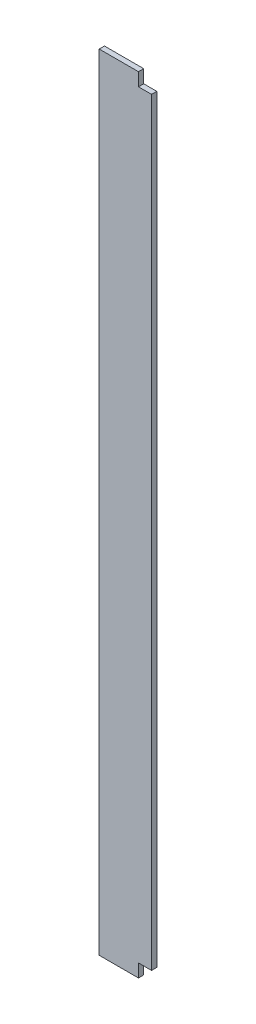
from build123d import *

# Parameters (mm, degrees)
ESBO_O1_W                = 200
ESBO_O1_H                = 20
RESSALTO_EXTRUS_O1_DEPTH = 3000
ESBO_O2_W                = 50
ESBO_O2_H                = 50
CORTE_EXTRUS_O1_DEPTH    = 21
ESBO_O3_W                = 50
ESBO_O3_H                = 50
CORTE_EXTRUS_O2_DEPTH    = 21


with BuildPart() as part:
    # Esboço1 → Ressalto-extrusão1 (new body)
    with BuildSketch(Plane(origin=(0, 0, 0), x_dir=(1, 0, 0), z_dir=(0, 1, 0))):
        with Locations((-1056.483688544, 794.687242443)):
            Rectangle(ESBO_O1_W, ESBO_O1_H)
    extrude(amount=RESSALTO_EXTRUS_O1_DEPTH)

    # Esboço2 → Corte-extrusão1 (cut, through all)
    with BuildSketch(Plane.XY.offset(-784.687242443)):
        with Locations((-981.483688544, 25)):
            Rectangle(ESBO_O2_W, ESBO_O2_H)
    extrude(amount=-CORTE_EXTRUS_O1_DEPTH, mode=Mode.SUBTRACT)

    # Esboço3 → Corte-extrusão2 (cut, through all)
    with BuildSketch(Plane.XY.offset(-784.687242443)):
        with Locations((-981.483688544, 2975)):
            Rectangle(ESBO_O3_W, ESBO_O3_H)
    extrude(amount=-CORTE_EXTRUS_O2_DEPTH, mode=Mode.SUBTRACT)


solid = part.part
